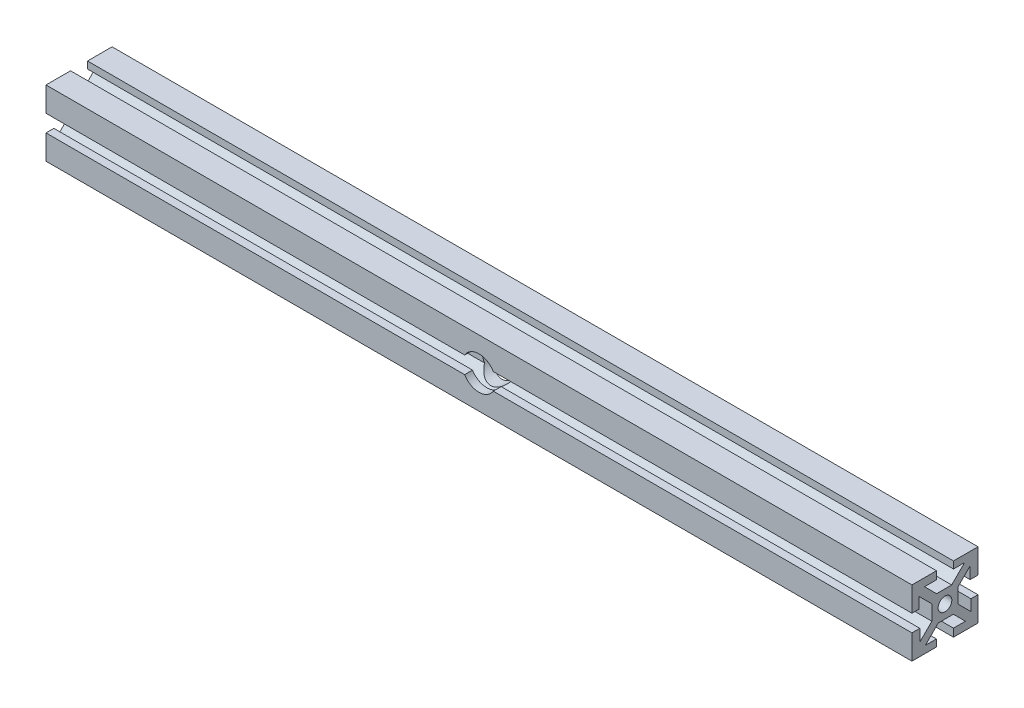
from build123d import *

# Parameters (mm, degrees)
SKETCH1_R           = 2.605
BOSS_EXTRUDE1_DEPTH = 330.2
CIRPATTERN1_COUNT   = 4
SKETCH2_R           = 6.35
CUT_EXTRUDE1_DEPTH  = 20


with BuildPart() as part:
    # Sketch1 → Boss-Extrude1 (new body)
    with BuildSketch(Plane(origin=(0, 0, 0), x_dir=(0, 0, -1), z_dir=(1, 0, 0))):
        Polygon((5, -5), (5, 3.203948776), (9.596194078, 7.800142853), (9.596194078, 3.24), (12.596194078, 3.24), (12.596194078, 12.596194078), (3.24, 12.596194078), (3.24, 9.921463197), (7.474873734, 9.921463197), (2.553410537, 5), (-5, 5), (-5, -5), align=None)
        Circle(SKETCH1_R, mode=Mode.SUBTRACT)
    boss_extrude1 = extrude(amount=BOSS_EXTRUDE1_DEPTH)

    # CirPattern1: Boss-Extrude1 ×4 about axis
    cirpattern1_axis = Axis((0, 0, 0), (1, 0, 0))
    for i in range(1, CIRPATTERN1_COUNT):
        add(boss_extrude1.rotate(cirpattern1_axis, i * 360 / CIRPATTERN1_COUNT))

    # Sketch2 → Cut-Extrude1 (cut)
    with BuildSketch(Plane.XY):
        with Locations((165.1, 0)):
            Circle(SKETCH2_R)
    extrude(amount=CUT_EXTRUDE1_DEPTH, mode=Mode.SUBTRACT)


solid = part.part
